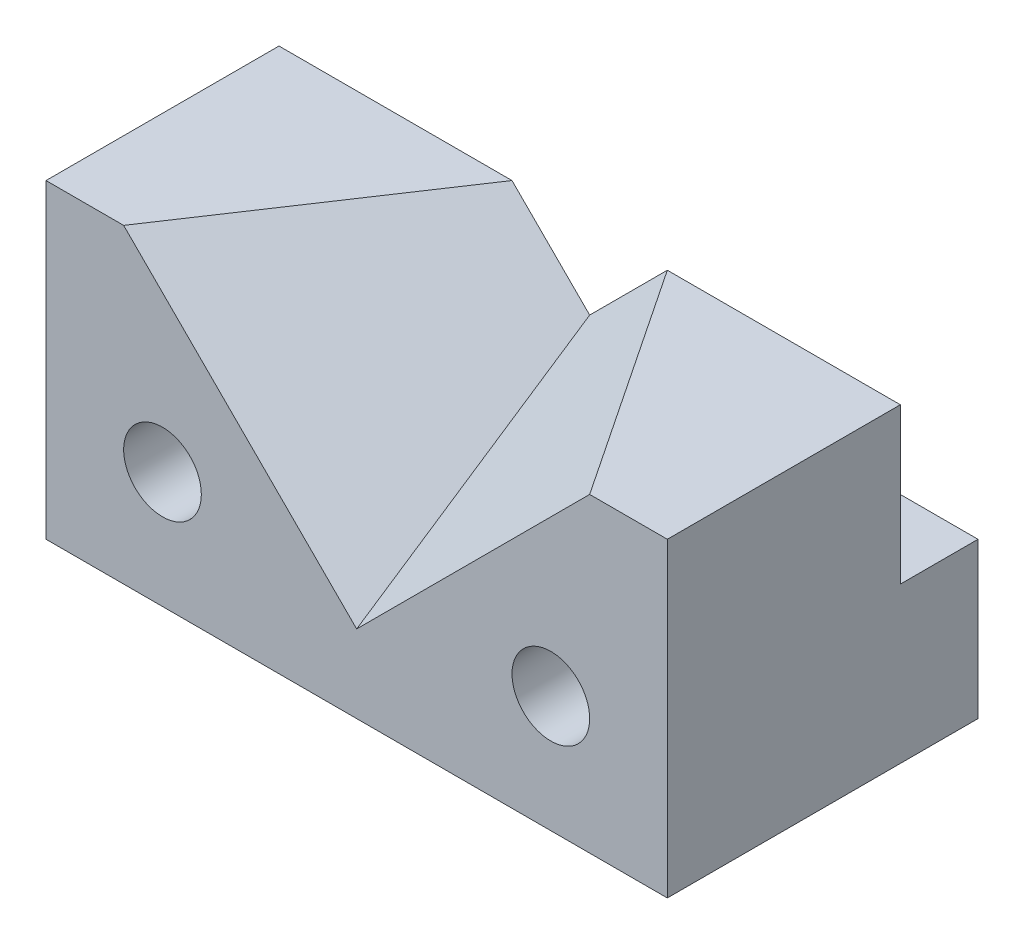
from build123d import *

# Parameters (mm, degrees)
IZIM1_W                     = 40
IZIM1_H                     = 20
Y_KSEKLIK_EKSTR_ZYON1_DEPTH = 20
IZIM2_R                     = 2.5
KES_EKSTR_ZYON1_DEPTH       = 20
IZIM3_W                     = 40
IZIM3_H                     = 5
KES_EKSTR_ZYON3_DEPTH       = 9
IZIM6_W                     = 40
IZIM6_H                     = 5
KES_EKSTR_ZYON13_DEPTH      = 1.001


with BuildPart() as part:
    # Çizim1 → Yükseklik-Ekstrüzyon1 (new body)
    with BuildSketch(Plane.XY):
        with Locations((20, 10)):
            Rectangle(IZIM1_W, IZIM1_H)
    extrude(amount=Y_KSEKLIK_EKSTR_ZYON1_DEPTH)

    # Çizim2 → Kes-Ekstrüzyon1 (cut)
    with BuildSketch(Plane.XY.offset(20)):
        with Locations((7.5, 7.5)):
            Circle(IZIM2_R)
        with Locations((32.5, 7.5)):
            Circle(IZIM2_R)
    extrude(amount=-KES_EKSTR_ZYON1_DEPTH, mode=Mode.SUBTRACT)

    # Çizim3 → Kes-Ekstrüzyon3 (cut)
    with BuildSketch(Plane(origin=(0, 20, 0), x_dir=(1, 0, 0), z_dir=(0, 1, 0))):
        with Locations((20, -2.5)):
            Rectangle(IZIM3_W, IZIM3_H)
    extrude(amount=-KES_EKSTR_ZYON3_DEPTH, mode=Mode.SUBTRACT)

    # Çizim5 → Kes-Loft2 section 0
    with BuildSketch(Plane(origin=(0, 0, 5), x_dir=(-1, 0, 0), z_dir=(0, 0, -1))):
        Polygon((-25, 20), (-20, 15), (-15, 20), align=None)
    # Çizim4 → Kes-Loft2 section 1
    with BuildSketch(Plane.XY.offset(20)):
        Polygon((5, 20), (20, 5), (35, 20), align=None)
    loft(mode=Mode.SUBTRACT)

    # Çizim6 → Kes-Ekstrüzyon13 (cut)
    with BuildSketch(Plane(origin=(0, 11, 0), x_dir=(1, 0, 0), z_dir=(0, 1, 0))):
        with Locations((20, -2.5)):
            Rectangle(IZIM6_W, IZIM6_H)
    extrude(amount=-KES_EKSTR_ZYON13_DEPTH, mode=Mode.SUBTRACT)


solid = part.part
